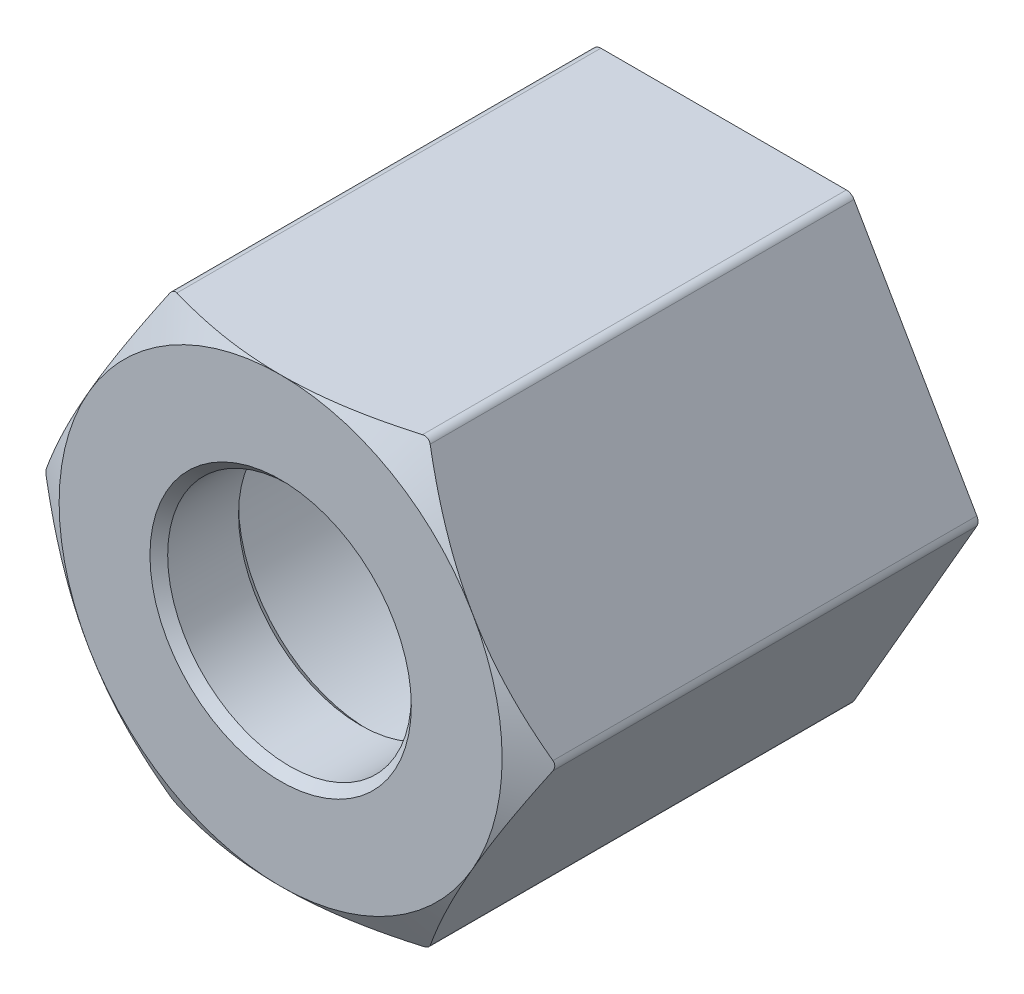
from build123d import *

# Parameters (mm, degrees)
ESTRUSIONE_ESTRUSIONE1_DEPTH = 10
SCHIZZO6_OUTSIDE_W           = 18.864
SCHIZZO6_OUTSIDE_H           = 17.316
SCHIZZO6_OUTSIDE_R           = 5
TAGLIO_ESTRUSIONE1_DEPTH     = 0.5
TAGLIO_ESTRUSIONE1_TAPER     = 59
RACCORDO1_R                  = 0.2
SCHIZZO19_R                  = 4
TAGLIO_ESTRUSIONE5_DEPTH     = 8
TAGLIO_ESTRUSIONE6_REACH     = 4
SCHIZZO20_R                  = 2.75
SMUSSO3_SIZE                 = 0.2


with BuildPart() as part:
    # Schizzo4 → Estrusione-Estrusione1 (new body)
    with BuildSketch(Plane.XY):
        Polygon((2.886751346, 5), (-2.886751346, 5), (-5.773502692, 0), (-2.886751346, -5), (2.886751346, -5), (5.773502692, 0), align=None)
    extrude(amount=-ESTRUSIONE_ESTRUSIONE1_DEPTH)

    # Schizzo6 outside → Taglio-Estrusione1 (cut)
    with BuildSketch(Plane.XY):
        Rectangle(SCHIZZO6_OUTSIDE_W, SCHIZZO6_OUTSIDE_H)
        Circle(SCHIZZO6_OUTSIDE_R, mode=Mode.SUBTRACT)
    extrude(amount=-TAGLIO_ESTRUSIONE1_DEPTH, taper=TAGLIO_ESTRUSIONE1_TAPER, mode=Mode.SUBTRACT)

    # Raccordo1
    raccordo1_edges = [part.edges().sort_by_distance(p)[0] for p in [
        (2.886751346, -5, -5.232383653),
        (-2.886751346, -5, -5.232383653),
        (-5.773502692, 0, -5.232383653),
        (-2.886751346, 5, -5.232383653),
        (2.886751346, 5, -5.232383653),
        (5.773502692, 0, -5.232383653),
    ]]
    fillet(raccordo1_edges, radius=RACCORDO1_R)

    # Schizzo19 → Taglio-Estrusione5 (cut)
    with BuildSketch(Plane(origin=(0, 0, -10), x_dir=(-1, 0, 0), z_dir=(0, 0, -1))):
        Circle(SCHIZZO19_R)
    extrude(amount=-TAGLIO_ESTRUSIONE5_DEPTH, mode=Mode.SUBTRACT)

    # Schizzo20 → Taglio-Estrusione6 (cut, up to next)
    with BuildSketch(Plane(origin=(0, 0, -2), x_dir=(-1, 0, 0), z_dir=(0, 0, -1)), mode=Mode.PRIVATE) as taglio_estrusione6_sk1:
        Circle(SCHIZZO20_R)
    taglio_estrusione6_tool1 = extrude(taglio_estrusione6_sk1.sketch, amount=-TAGLIO_ESTRUSIONE6_REACH, mode=Mode.PRIVATE) & part.part
    add(taglio_estrusione6_tool1.solids().sort_by_distance((0, 0, -2))[0], mode=Mode.SUBTRACT)

    # Smusso3
    smusso3_edges = [part.edges().sort_by_distance(p)[0] for p in [
        (4, 0, -10),
        (2.75, 0, 0),
        (2.75, 0, -2),
    ]]
    chamfer(smusso3_edges, length=SMUSSO3_SIZE)


solid = part.part
